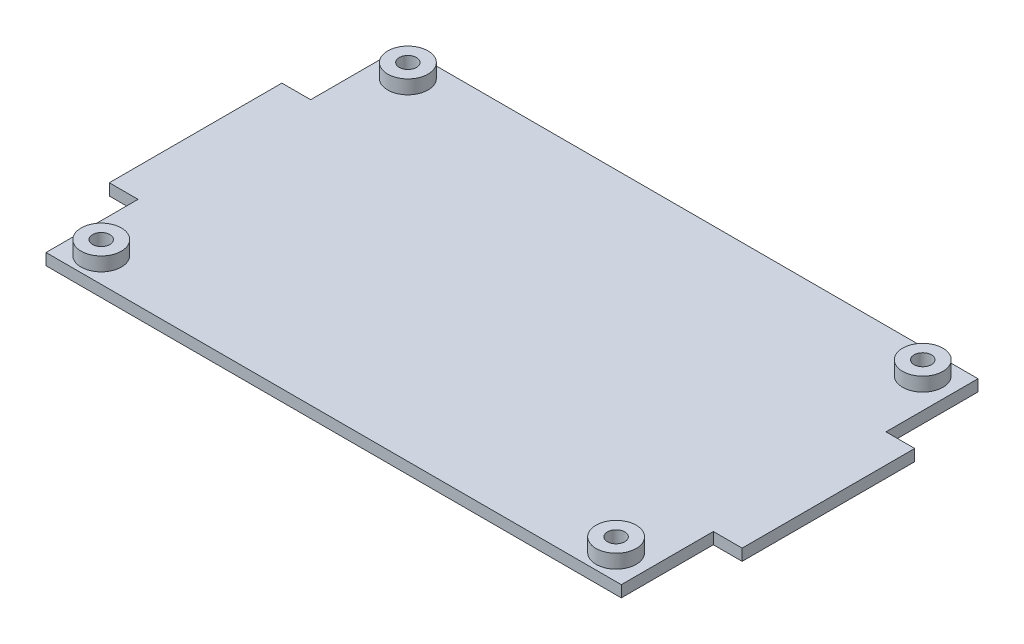
from build123d import *

# Parameters (mm, degrees)
SKETCH_1_W            = 100
SKETCH_1_H            = 62
SKETCH_1_W_2          = 110
SKETCH_1_H_2          = 30
EXTRUDE_466_DEPTH     = 2
SKETCH_2_R            = 1.5
CUT_EXTRUDE_826_DEPTH = 2
SKETCH_3_R            = 3.5
SKETCH_3_R_2          = 1.5
EXTRUDE_1142_DEPTH    = 2.4


with BuildPart() as part:
    # 草图1 → Extrude 466 (new body)
    with BuildSketch(Plane(origin=(0, 0, 0), x_dir=(1, 0, 0), z_dir=(0, 1, 0))):
        Rectangle(SKETCH_1_W, SKETCH_1_H)
        Rectangle(SKETCH_1_W_2, SKETCH_1_H_2)
    extrude(amount=EXTRUDE_466_DEPTH)

    # 草图2 → Cut-Extrude 826 (cut)
    with BuildSketch(Plane(origin=(0, 2, 0), x_dir=(1, 0, 0), z_dir=(0, 1, 0))):
        with Locations((-44.75, 26.65)):
            Circle(SKETCH_2_R)
        with Locations((44.75, 26.65)):
            Circle(SKETCH_2_R)
        with Locations((-44.75, -26.65)):
            Circle(SKETCH_2_R)
        with Locations((44.75, -26.65)):
            Circle(SKETCH_2_R)
    extrude(amount=-CUT_EXTRUDE_826_DEPTH, mode=Mode.SUBTRACT)

    # 草图3 → Extrude 1142 (add)
    with BuildSketch(Plane(origin=(0, 2, 0), x_dir=(1, 0, 0), z_dir=(0, 1, 0))):
        with Locations((-44.75, 26.65)):
            Circle(SKETCH_3_R)
        with Locations((-44.75, 26.65)):
            Circle(SKETCH_3_R_2, mode=Mode.SUBTRACT)
        with Locations((44.75, 26.65)):
            Circle(SKETCH_3_R)
        with Locations((44.75, 26.65)):
            Circle(SKETCH_3_R_2, mode=Mode.SUBTRACT)
        with Locations((-44.75, -26.65)):
            Circle(SKETCH_3_R)
        with Locations((-44.75, -26.65)):
            Circle(SKETCH_3_R_2, mode=Mode.SUBTRACT)
        with Locations((44.75, -26.65)):
            Circle(SKETCH_3_R)
        with Locations((44.75, -26.65)):
            Circle(SKETCH_3_R_2, mode=Mode.SUBTRACT)
    extrude(amount=EXTRUDE_1142_DEPTH)


solid = part.part
